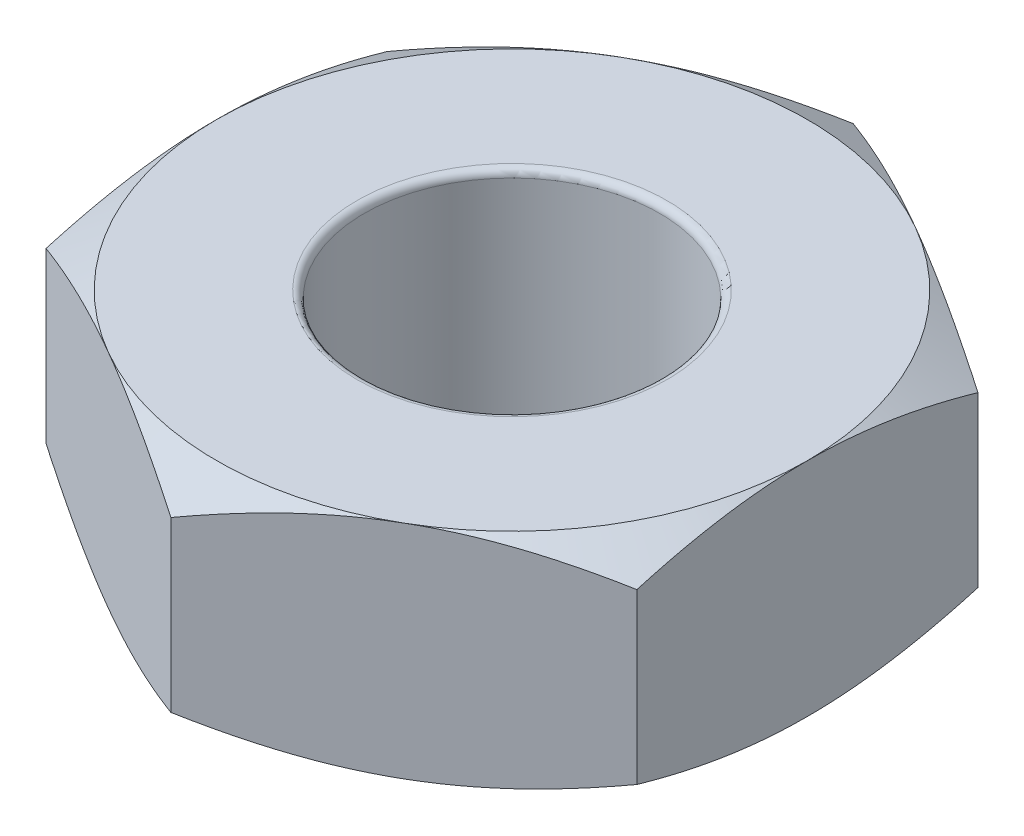
from build123d import *

# Parameters (mm, degrees)
SKETCH2_R           = 1
BOSS_EXTRUDE1_DEPTH = 1.5
SKETCH3_OUTSIDE_W   = 14.186
SKETCH3_OUTSIDE_H   = 14.804
SKETCH3_OUTSIDE_R   = 2
CUT_EXTRUDE1_DEPTH  = 2
CUT_EXTRUDE1_TAPER  = 60
SKETCH4_OUTSIDE_W   = 14.186
SKETCH4_OUTSIDE_H   = 14.804
SKETCH4_OUTSIDE_R   = 2
CUT_EXTRUDE2_DEPTH  = 2
CUT_EXTRUDE2_TAPER  = 60
FILLET1_R           = 0.05


with BuildPart() as part:
    # Sketch2 → Boss-Extrude1 (new body)
    with BuildSketch(Plane(origin=(0, 0, 0), x_dir=(1, 0, 0), z_dir=(0, 1, 0))):
        Polygon((2, -1.154700538), (2, 1.154700538), (0, 2.309401077), (-2, 1.154700538), (-2, -1.154700538), (0, -2.309401077), align=None)
        Circle(SKETCH2_R, mode=Mode.SUBTRACT)
    extrude(amount=BOSS_EXTRUDE1_DEPTH)

    # Sketch3 outside → Cut-Extrude1 (cut)
    with BuildSketch(Plane(origin=(0, 1.5, 0), x_dir=(1, 0, 0), z_dir=(0, 1, 0))):
        Rectangle(SKETCH3_OUTSIDE_W, SKETCH3_OUTSIDE_H)
        Circle(SKETCH3_OUTSIDE_R, mode=Mode.SUBTRACT)
    extrude(amount=-CUT_EXTRUDE1_DEPTH, taper=CUT_EXTRUDE1_TAPER, mode=Mode.SUBTRACT)

    # Sketch4 outside → Cut-Extrude2 (cut)
    with BuildSketch(Plane.XZ):
        Rectangle(SKETCH4_OUTSIDE_W, SKETCH4_OUTSIDE_H)
        Circle(SKETCH4_OUTSIDE_R, mode=Mode.SUBTRACT)
    extrude(amount=-CUT_EXTRUDE2_DEPTH, taper=CUT_EXTRUDE2_TAPER, mode=Mode.SUBTRACT)

    # Fillet1
    fillet1_edges = [part.edges().sort_by_distance(p)[0] for p in [
        (-1, 0, 0),
        (-1, 1.5, 0),
    ]]
    fillet(fillet1_edges, radius=FILLET1_R)


solid = part.part
